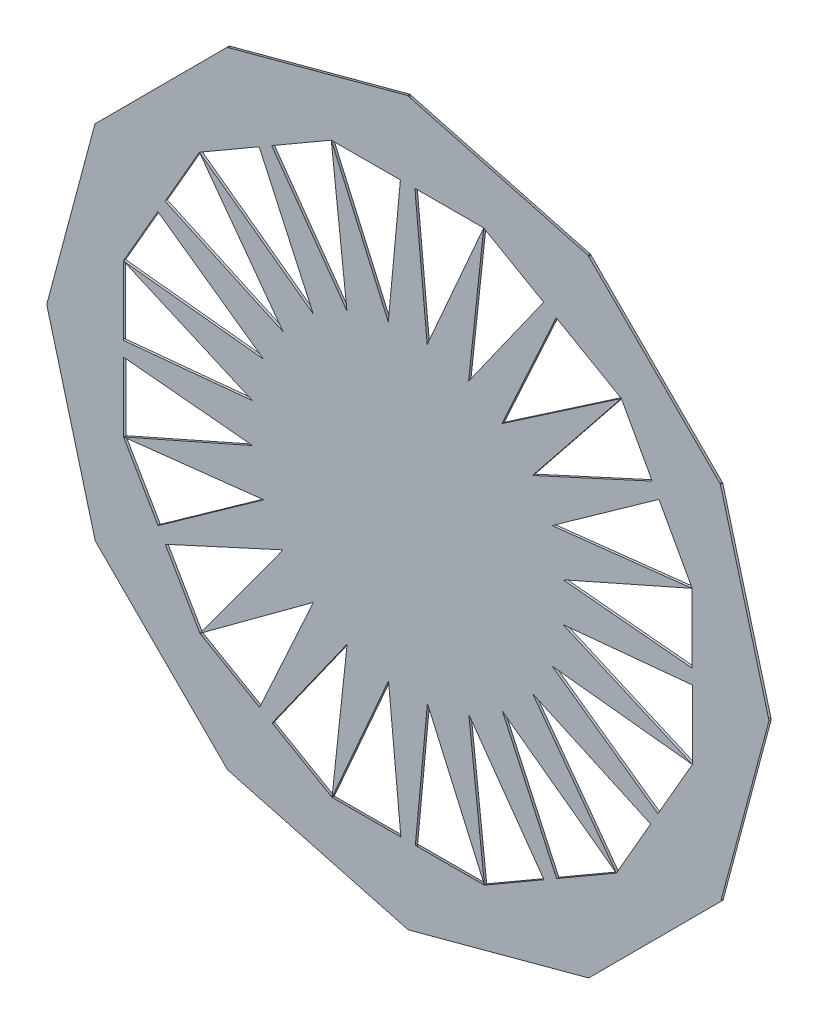
from build123d import *

# Parameters (mm, degrees)
SALIENTE_EXTRUIR1_DEPTH = 0.1


with BuildPart() as part:
    # Model → Saliente-Extruir1 (new body)
    with BuildSketch(Plane.XY):
        Polygon((38.934856987, 3.809675647), (36.434205202, 9.464663467), (35.591222833, 0.441711008), (34.729963486, 9.463480413), (32.252995163, 3.800796402), (32.914861102, 9.948485405), (27.673340726, 2.555870543), (31.438352954, 10.799581708), (26.461893457, 7.134037663), (30.108930676, 12.127159545), (21.873333444, 8.345727462), (29.255785262, 13.602484638), (23.113272894, 12.916260125), (28.768260715, 15.416911909), (19.745308255, 16.259894278), (28.76707766, 17.121153626), (23.10439365, 19.598121949), (29.252082653, 18.936256009), (21.85946779, 24.177776386), (30.103178956, 20.412764157), (26.43763491, 25.389223655), (31.430756792, 21.742186436), (27.649324709, 29.977783667), (32.906081885, 22.595331849), (32.219857372, 28.737844218), (34.720509156, 23.082856397), (35.563491526, 32.105808856), (36.424750873, 23.084039451), (38.901719196, 28.746723462), (38.239853257, 22.599034459), (43.481373633, 29.991649321), (39.701904091, 21.716283034), (44.937970468, 25.290093704), (41.045783683, 20.420360319), (49.281380915, 24.201792402), (41.898929097, 18.945035226), (48.041441465, 19.631259739), (42.386453644, 17.130607955), (51.409406103, 16.287625586), (42.387636698, 15.426366239), (48.050320709, 12.949397916), (41.902631706, 13.611263855), (49.295246568, 8.369743478), (41.051535403, 12.134755707), (44.717079448, 7.158296209), (39.723957567, 10.805333428), (43.50538965, 2.569736197), (38.248632473, 9.952188015), align=None)
    extrude(amount=SALIENTE_EXTRUIR1_DEPTH)


solid = part.part
